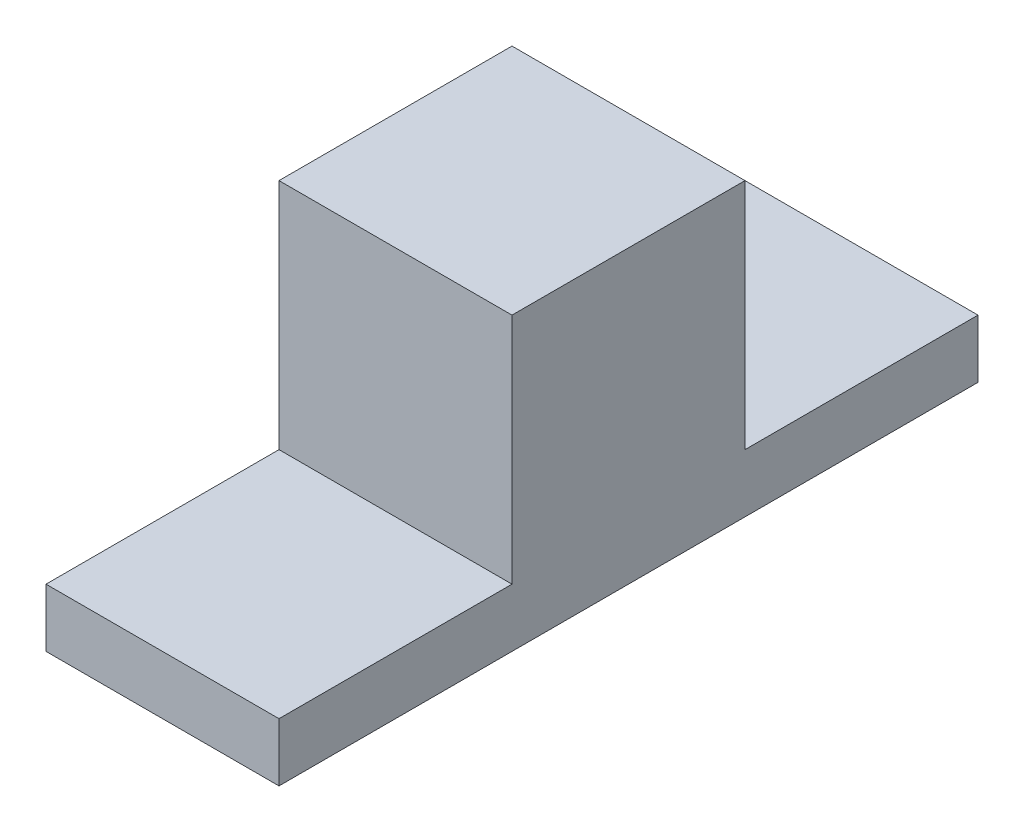
from build123d import *

# Parameters (mm, degrees)
BOSS_EXTRUDE1_DEPTH = 6.35


with BuildPart() as part:
    # Sketch2 → Boss-Extrude1 (new body)
    with BuildSketch(Plane(origin=(0, 0, 0), x_dir=(0, 0, -1), z_dir=(1, 0, 0))):
        Polygon((3.175, 0), (9.525, 0), (9.525, -1.5875), (-9.525, -1.5875), (-9.525, 0), (-3.175, 0), (-3.175, 6.35), (3.175, 6.35), align=None)
    extrude(amount=BOSS_EXTRUDE1_DEPTH)


solid = part.part
